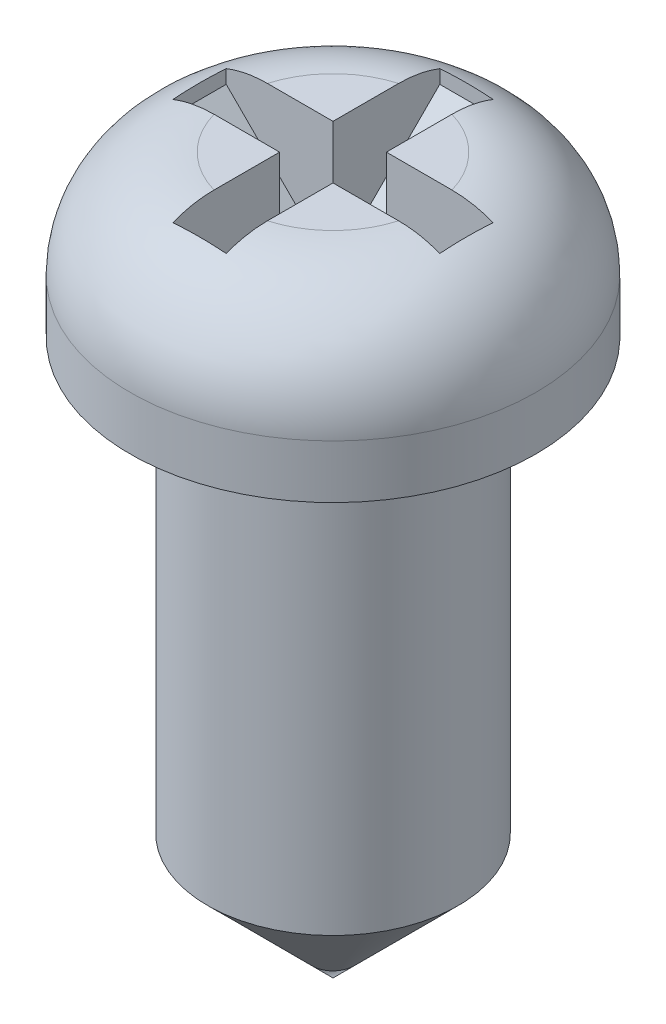
from build123d import *

# Parameters (mm, degrees)
CUT_EXTRUDE1_DEPTH = 1
CHAMFER1_SIZE      = 0.8


with BuildPart() as part:
    # Sketch1 → Revolve1 (revolve)
    with BuildSketch(Plane.XY):
        with BuildLine():
            Line((1.175, 0), (1.9, 0))
            Line((1.9, 0), (1.9, 0.5))
            ThreePointArc((1.9, 0.5), (1.607106781, 1.207106781), (0.9, 1.5))
            Line((0.9, 1.5), (0, 1.5))
            Line((0, 1.5), (0, -5.2))
            Line((0, -5.2), (1.175, -4.025))
            Line((1.175, -4.025), (1.175, 0))
        make_face()
    revolve(axis=Axis((0, -5.2, 0), (0, -1, 0)))

    # Sketch2 → Cut-Extrude1 (cut)
    with BuildSketch(Plane(origin=(0, 1.5, 0), x_dir=(1, 0, 0), z_dir=(0, 1, 0))):
        Polygon((0.25, 0.25), (1.25, 0.25), (1.25, -0.25), (0.25, -0.25), (0.25, -1.25), (-0.25, -1.25), (-0.25, -0.25), (-1.25, -0.25), (-1.25, 0.25), (-0.25, 0.25), (-0.25, 1.25), (0.25, 1.25), align=None)
    extrude(amount=-CUT_EXTRUDE1_DEPTH, mode=Mode.SUBTRACT)

    # Chamfer1
    chamfer1_edges = [part.edges().sort_by_distance(p)[0] for p in [
        (1.25, 0.5, 0),
        (0, 0.5, 1.25),
        (-1.25, 0.5, 0),
        (0, 0.5, -1.25),
    ]]
    chamfer(chamfer1_edges, length=CHAMFER1_SIZE)


solid = part.part
